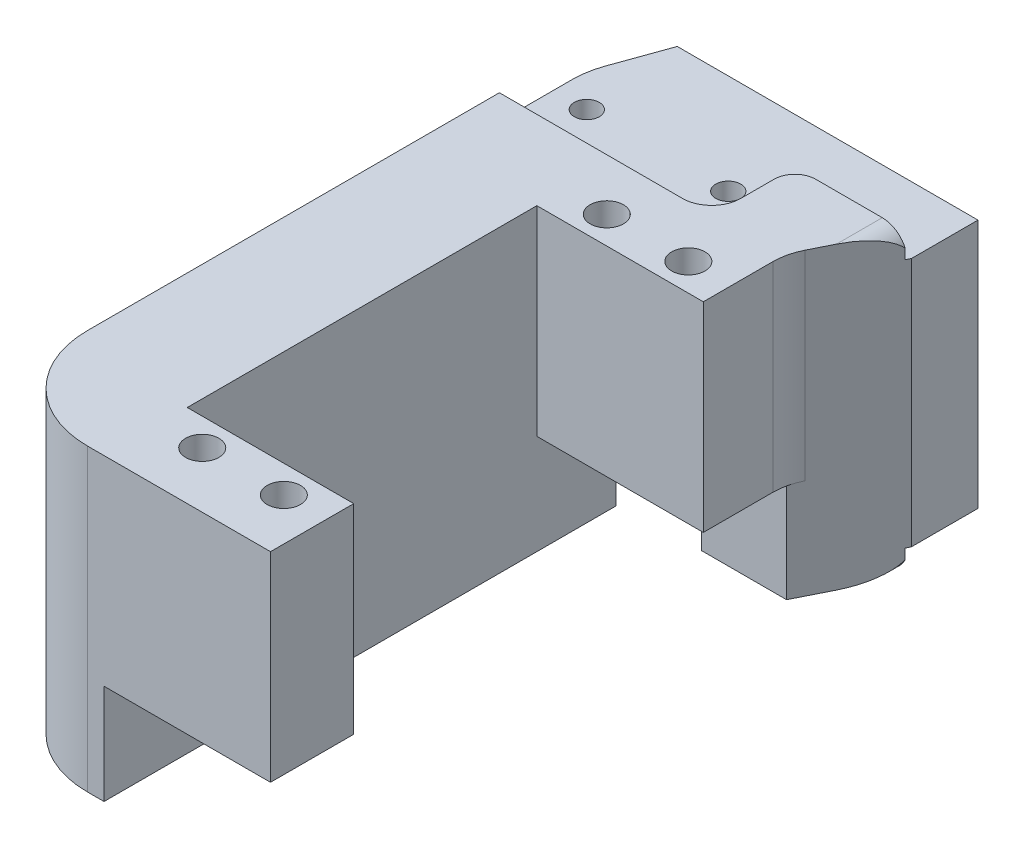
from build123d import *

# Parameters (mm, degrees)
BOSS_EXTRUDE1_DEPTH     = 36
CUT_EXTRUDE2_DEPTH      = 3
CUT_EXTRUDE3_DEPTH      = 3
FILLET3_R               = 12
SKETCH5_W               = 25.000013064
SKETCH5_H               = 10
SKETCH5_H_2             = 9.999999996
CUT_EXTRUDE4_DEPTH      = 12
CUT_EXTRUDE5_DEPTH      = 13
CUT_EXTRUDE5_DEPTH_BACK = 25
FILLET4_R               = 7
CUT_EXTRUDE6_DEPTH      = 1
CUT_EXTRUDE6_DEPTH_BACK = 81
SKETCH8_R               = 1.5
SKETCH8_R_2             = 2
CUT_EXTRUDE7_DEPTH      = 34


with BuildPart() as part:
    # Sketch1 → Boss-Extrude1 (new body)
    with BuildSketch(Plane.XZ.offset(-33.496710387)):
        with BuildLine():
            Line((-28.572528903, 54.343907724), (-28.572528903, 64.34390772))
            Line((-28.572528903, 64.34390772), (-67.573393535, 64.34390772))
            Line((-67.573393535, 64.34390772), (-67.573393535, -5.916364341))
            ThreePointArc((-67.573393535, -5.916364341), (-67.425411698, -7.63034746), (-66.98584591, -9.293602903))
            Line((-66.98584591, -9.293602903), (-64.702950485, -15.65609228))
            Line((-64.702950485, -15.65609228), (-28.572528903, -15.65609228))
            Line((-28.572528903, -15.65609228), (-28.572528903, 12.343907724))
            Line((-28.572528903, 12.343907724), (-53.572541967, 12.343907724))
            Line((-53.572541967, 12.343907724), (-53.572541967, 54.343907724))
            Line((-53.572541967, 54.343907724), (-28.572528903, 54.343907724))
        make_face()
    extrude(amount=BOSS_EXTRUDE1_DEPTH)

    # Sketch3 → Cut-Extrude2 (cut)
    with BuildSketch(Plane.XZ.offset(2.503289613)):
        with BuildLine():
            Line((-28.572528903, -15.65609228), (-67.573393527, -15.65609228))
            Line((-67.573393527, -15.65609228), (-67.573393527, 2.843907727))
            Line((-67.573393527, 2.843907727), (-45.573393535, 2.843907727))
            ThreePointArc((-45.573393535, 2.843907727), (-43.098519801, 1.818781461), (-42.073393535, -0.656092273))
            Line((-42.073393535, -0.656092273), (-42.073393535, -4.656092274))
            ThreePointArc((-42.073393535, -4.656092274), (-41.341160488, -6.423859227), (-39.573393535, -7.156092274))
            Line((-39.573393535, -7.156092274), (-28.572528903, -7.156092274))
            Line((-28.572528903, -7.156092274), (-28.572528903, -15.65609228))
        make_face()
    extrude(amount=-CUT_EXTRUDE2_DEPTH, mode=Mode.SUBTRACT)

    # Sketch4 → Cut-Extrude3 (cut)
    with BuildSketch(Plane(origin=(0, 33.496710387, 0), x_dir=(1, 0, 0), z_dir=(0, 1, 0))):
        with BuildLine():
            Line((-67.573393527, 15.65609228), (-67.573393527, -2.843907727))
            Line((-67.573393527, -2.843907727), (-45.573393535, -2.843907727))
            ThreePointArc((-45.573393535, -2.843907727), (-43.098519801, -1.818781461), (-42.073393535, 0.656092273))
            Line((-42.073393535, 0.656092273), (-42.073393535, 4.656092274))
            ThreePointArc((-42.073393535, 4.656092274), (-41.341160488, 6.423859227), (-39.573393535, 7.156092274))
            Line((-39.573393535, 7.156092274), (-28.572528903, 7.156092274))
            Line((-28.572528903, 7.156092274), (-28.572528903, 15.65609228))
            Line((-28.572528903, 15.65609228), (-67.573393527, 15.65609228))
        make_face()
    extrude(amount=-CUT_EXTRUDE3_DEPTH, mode=Mode.SUBTRACT)

    # Fillet3
    fillet3_edges = [part.edges().sort_by_distance(p)[0] for p in [
        (-67.573393535, 15.496710387, 64.34390772),
    ]]
    fillet(fillet3_edges, radius=FILLET3_R)

    # Sketch5 → Cut-Extrude4 (cut)
    with BuildSketch(Plane.XZ.offset(2.503289613)):
        with Locations((-41.072535435, 7.343907724)):
            Rectangle(SKETCH5_W, SKETCH5_H)
        with Locations((-41.072535435, 59.343907722)):
            Rectangle(SKETCH5_W, SKETCH5_H_2)
    extrude(amount=-CUT_EXTRUDE4_DEPTH, mode=Mode.SUBTRACT)

    # Sketch6 → Cut-Extrude5 (cut, two sides)
    with BuildSketch(Plane.XZ.offset(-9.496710387)) as cut_extrude5_sk:
        Polygon((-33.572541967, 64.34390772), (-33.572541967, 2.343907724), (-28.572528903, -7.656092278), (-28.572528903, 64.34390772), align=None)
    extrude(amount=CUT_EXTRUDE5_DEPTH, mode=Mode.SUBTRACT)
    extrude(cut_extrude5_sk.sketch, amount=-CUT_EXTRUDE5_DEPTH_BACK, mode=Mode.SUBTRACT)

    # Fillet4
    fillet4_edges = [part.edges().sort_by_distance(p)[0] for p in [
        (-33.572541967, 21.496710387, 2.343907724),
    ]]
    fillet(fillet4_edges, radius=FILLET4_R)

    # Sketch7 → Cut-Extrude6 (cut, two sides)
    with BuildSketch(Plane(origin=(0, 0, -15.65609228), x_dir=(-1, 0, 0), z_dir=(0, 0, -1))) as cut_extrude6_sk:
        with BuildLine():
            Line((31.572528926, -2.503289613), (28.572528926, -2.503289613))
            Line((28.572528926, -2.503289613), (28.572528926, 0.496710387))
            ThreePointArc((28.572528926, 0.496710387), (29.451208582, -1.624609954), (31.572528926, -2.503289613))
        make_face()
        with BuildLine():
            Line((31.572528902, 33.496710387), (28.572528902, 33.496710387))
            Line((28.572528902, 33.496710387), (28.572528902, 30.496710387))
            ThreePointArc((28.572528902, 30.496710387), (29.451208558, 32.618030731), (31.572528902, 33.496710387))
        make_face()
    extrude(amount=CUT_EXTRUDE6_DEPTH, mode=Mode.SUBTRACT)
    extrude(cut_extrude6_sk.sketch, amount=-CUT_EXTRUDE6_DEPTH_BACK, mode=Mode.SUBTRACT)

    # Sketch8 → Cut-Extrude7 (cut, through all)
    with BuildSketch(Plane.XZ.offset(-0.496710387)):
        with Locations((-46.573393534, -3.65609228)):
            Circle(SKETCH8_R)
        with Locations((-63.573393534, -3.656092278)):
            Circle(SKETCH8_R)
        with Locations((-38.672541967, 9.043907724)):
            Circle(SKETCH8_R_2)
        with Locations((-48.472541967, 9.043907724)):
            Circle(SKETCH8_R_2)
        with Locations((-48.472541967, 57.643907724)):
            Circle(SKETCH8_R_2)
        with Locations((-38.672541967, 57.643907724)):
            Circle(SKETCH8_R_2)
    extrude(amount=-CUT_EXTRUDE7_DEPTH, mode=Mode.SUBTRACT)


solid = part.part
